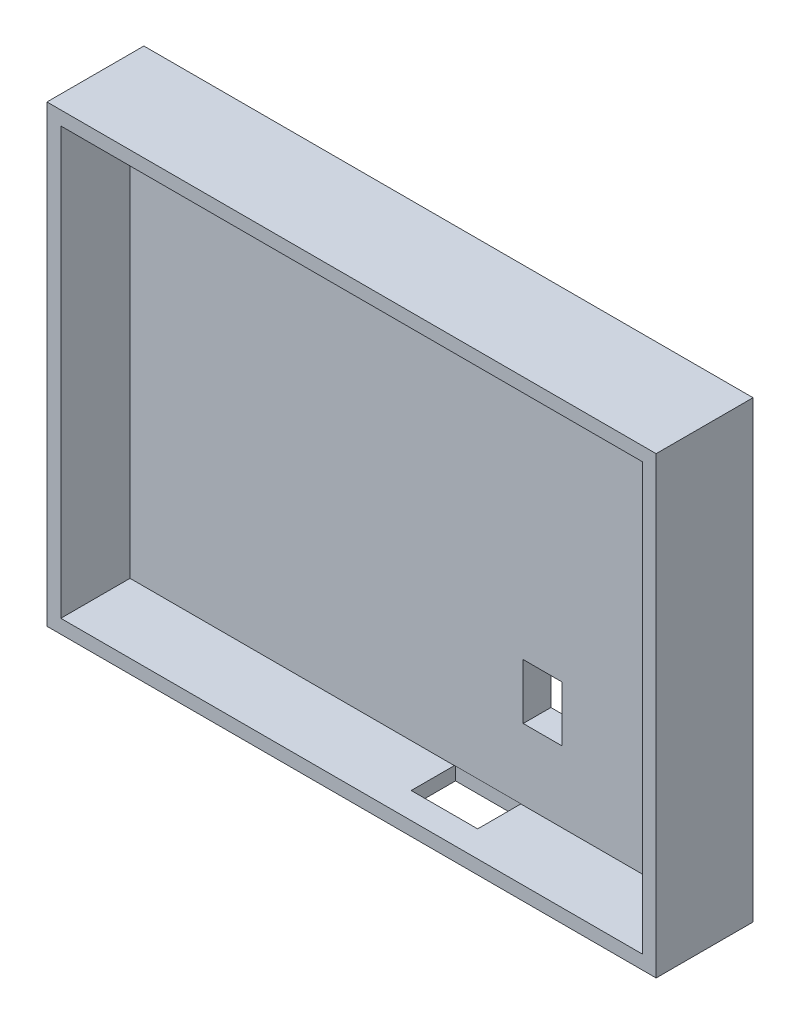
from build123d import *

# Parameters (mm, degrees)
SKETCH1_W           = 110
SKETCH1_H           = 82
BOSS_EXTRUDE1_DEPTH = 5
SKETCH3_W           = 110
SKETCH3_H           = 2.5
BOSS_EXTRUDE2_DEPTH = 12.5
SKETCH4_W           = 2.5
SKETCH4_H           = 79.5
BOSS_EXTRUDE3_DEPTH = 12.5
SKETCH5_W           = 107.5
SKETCH5_H           = 2.5
BOSS_EXTRUDE4_DEPTH = 12.5
SKETCH6_W           = 2.5
SKETCH6_H           = 77
BOSS_EXTRUDE5_DEPTH = 12.5
SKETCH7_W           = 7
SKETCH7_H           = 10
CUT_EXTRUDE1_DEPTH  = 12.5
SKETCH8_W           = 12
SKETCH8_H           = 8
CUT_EXTRUDE2_DEPTH  = 2.54


with BuildPart() as part:
    # Sketch1 → Boss-Extrude1 (new body)
    with BuildSketch(Plane.XY):
        Rectangle(SKETCH1_W, SKETCH1_H)
    extrude(amount=BOSS_EXTRUDE1_DEPTH)

    # Sketch3 → Boss-Extrude2 (add)
    with BuildSketch(Plane.XY.offset(5)):
        with Locations((0, 39.75)):
            Rectangle(SKETCH3_W, SKETCH3_H)
    extrude(amount=BOSS_EXTRUDE2_DEPTH)

    # Sketch4 → Boss-Extrude3 (add)
    with BuildSketch(Plane.XY.offset(5)):
        with Locations((-53.75, -1.25)):
            Rectangle(SKETCH4_W, SKETCH4_H)
    extrude(amount=BOSS_EXTRUDE3_DEPTH)

    # Sketch5 → Boss-Extrude4 (add)
    with BuildSketch(Plane.XY.offset(5)):
        with Locations((1.25, -39.75)):
            Rectangle(SKETCH5_W, SKETCH5_H)
    extrude(amount=BOSS_EXTRUDE4_DEPTH)

    # Sketch6 → Boss-Extrude5 (add)
    with BuildSketch(Plane.XY.offset(5)):
        with Locations((53.75, 0)):
            Rectangle(SKETCH6_W, SKETCH6_H)
    extrude(amount=BOSS_EXTRUDE5_DEPTH)

    # Sketch7 → Cut-Extrude1 (cut)
    with BuildSketch(Plane.XY.offset(5)):
        with Locations((22, -20.7)):
            Rectangle(SKETCH7_W, SKETCH7_H)
    extrude(amount=-CUT_EXTRUDE1_DEPTH, mode=Mode.SUBTRACT)

    # Sketch8 → Cut-Extrude2 (cut)
    with BuildSketch(Plane.XZ.offset(41)):
        with Locations((12.06587737, 8.792437031)):
            Rectangle(SKETCH8_W, SKETCH8_H)
    extrude(amount=-CUT_EXTRUDE2_DEPTH, mode=Mode.SUBTRACT)


solid = part.part
